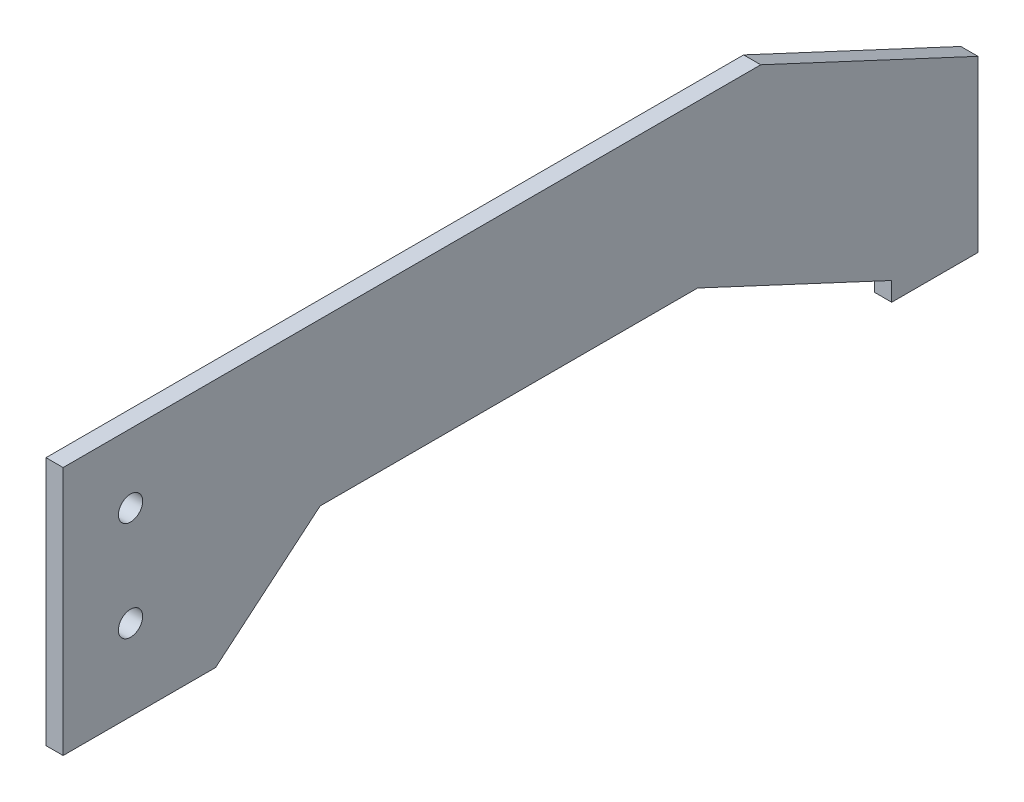
from build123d import *

# Parameters (mm, degrees)
SKETCH1_R           = 2.25
BOSS_EXTRUDE2_DEPTH = 3.175


with BuildPart() as part:
    # Sketch1 → Boss-Extrude2 (new body)
    with BuildSketch(Plane(origin=(0, 0, 0), x_dir=(0, 0, -1), z_dir=(1, 0, 0))):
        Polygon((-70.039073078, -1.218967506), (59.322512202, -1.218967506), (99.611526043, -20.0060432), (99.611526043, -51.5060432), (83.611526043, -51.5060432), (83.611526043, -48.0060432), (47.611526043, -31.218967506), (-22.388473957, -31.218967506), (-41.758526434, -47.472371395), (-70.039073078, -47.472371395), align=None)
        with Locations((-57.538473957, -13.972371395)):
            Circle(SKETCH1_R, mode=Mode.SUBTRACT)
        with Locations((-57.538473957, -32.472371395)):
            Circle(SKETCH1_R, mode=Mode.SUBTRACT)
    extrude(amount=BOSS_EXTRUDE2_DEPTH)


solid = part.part
